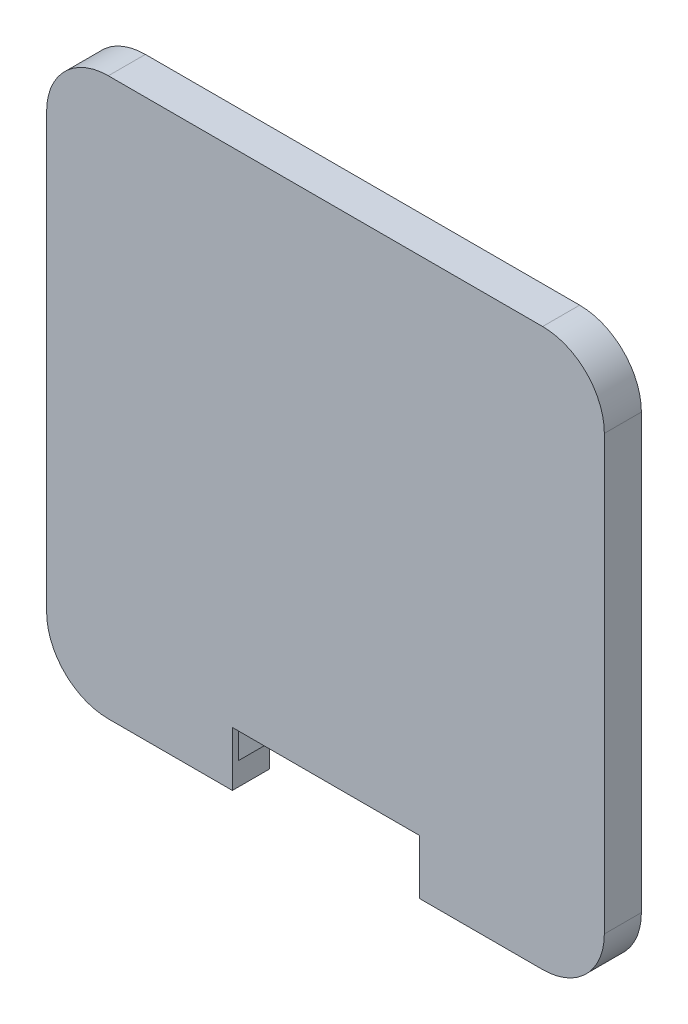
from build123d import *

# Parameters (mm, degrees)
BOSS_EXTRUDE1_DEPTH = 5
BOSS_EXTRUDE2_DEPTH = 1


with BuildPart() as part:
    # Sketch1 → Boss-Extrude1 (new body)
    with BuildSketch(Plane.XY):
        with BuildLine():
            Line((19.723160965, -30.122), (15.214660965, -41.425))
            Line((15.214660965, -41.425), (15.214660965, -45.122))
            Line((15.214660965, -45.122), (35.1855, -45.122))
            ThreePointArc((35.1855, -45.122), (42.256567812, -42.193067812), (45.1855, -35.122))
            Line((45.1855, -35.122), (45.1855, -30.122))
            Line((45.1855, -30.122), (45.1855, 35.122))
            ThreePointArc((45.1855, 35.122), (42.256567812, 42.193067812), (35.1855, 45.122))
            Line((35.1855, 45.122), (-35.1855, 45.122))
            ThreePointArc((-35.1855, 45.122), (-42.256567812, 42.193067812), (-45.1855, 35.122))
            Line((-45.1855, 35.122), (-45.1855, -30.122))
            Line((-45.1855, -30.122), (-45.1855, -35.122))
            ThreePointArc((-45.1855, -35.122), (-42.256567812, -42.193067812), (-35.1855, -45.122))
            Line((-35.1855, -45.122), (-15.086607553, -45.122))
            Line((-15.086607553, -45.122), (-15.086607553, -41.425))
            Line((-15.086607553, -41.425), (-19.722107553, -30.122))
            Line((-19.722107553, -30.122), (-24.9555, -30.122))
            ThreePointArc((-24.9555, -30.122), (-28.653668466, -28.590168466), (-30.1855, -24.892))
            Line((-30.1855, -24.892), (-30.1855, 24.892))
            ThreePointArc((-30.1855, 24.892), (-28.653668466, 28.590168466), (-24.9555, 30.122))
            Line((-24.9555, 30.122), (24.9555, 30.122))
            ThreePointArc((24.9555, 30.122), (28.653668466, 28.590168466), (30.1855, 24.892))
            Line((30.1855, 24.892), (30.1855, -24.892))
            ThreePointArc((30.1855, -24.892), (28.653668466, -28.590168466), (24.9555, -30.122))
            Line((24.9555, -30.122), (19.723160965, -30.122))
        make_face()
    extrude(amount=-BOSS_EXTRUDE1_DEPTH)

    # Sketch2 → Boss-Extrude2 (add)
    with BuildSketch(Plane.XY):
        with BuildLine():
            Line((-24.9555, 30.122), (24.9555, 30.122))
            ThreePointArc((24.9555, 30.122), (28.653668466, 28.590168466), (30.1855, 24.892))
            Line((30.1855, 24.892), (30.1855, -24.892))
            ThreePointArc((30.1855, -24.892), (28.653668466, -28.590168466), (24.9555, -30.122))
            Line((24.9555, -30.122), (19.723160965, -30.122))
            Line((19.723160965, -30.122), (15.214660965, -41.425))
            Line((15.214660965, -41.425), (15.214660965, -45.122))
            Line((15.214660965, -45.122), (35.1855, -45.122))
            ThreePointArc((35.1855, -45.122), (42.256567812, -42.193067812), (45.1855, -35.122))
            Line((45.1855, -35.122), (45.1855, 35.122))
            ThreePointArc((45.1855, 35.122), (42.256567812, 42.193067812), (35.1855, 45.122))
            Line((35.1855, 45.122), (-35.1855, 45.122))
            ThreePointArc((-35.1855, 45.122), (-42.256567812, 42.193067812), (-45.1855, 35.122))
            Line((-45.1855, 35.122), (-45.1855, -35.122))
            ThreePointArc((-45.1855, -35.122), (-42.256567812, -42.193067812), (-35.1855, -45.122))
            Line((-35.1855, -45.122), (-15.086607553, -45.122))
            Line((-15.086607553, -45.122), (-15.086607553, -41.425))
            Line((-15.086607553, -41.425), (-19.722107553, -30.122))
            Line((-19.722107553, -30.122), (-24.9555, -30.122))
            ThreePointArc((-24.9555, -30.122), (-28.653668466, -28.590168466), (-30.1855, -24.892))
            Line((-30.1855, -24.892), (-30.1855, 24.892))
            ThreePointArc((-30.1855, 24.892), (-28.653668466, 28.590168466), (-24.9555, 30.122))
        make_face()
        with BuildLine():
            Line((-19.722107553, -30.122), (-15.086607553, -41.425))
            Line((-15.086607553, -41.425), (-15.086607553, -36.275))
            Line((-15.086607553, -36.275), (15.214660965, -36.275))
            Line((15.214660965, -36.275), (15.214660965, -41.425))
            Line((15.214660965, -41.425), (19.723160965, -30.122))
            Line((19.723160965, -30.122), (24.9555, -30.122))
            ThreePointArc((24.9555, -30.122), (28.653668466, -28.590168466), (30.1855, -24.892))
            Line((30.1855, -24.892), (30.1855, 24.892))
            ThreePointArc((30.1855, 24.892), (28.653668466, 28.590168466), (24.9555, 30.122))
            Line((24.9555, 30.122), (-24.9555, 30.122))
            ThreePointArc((-24.9555, 30.122), (-28.653668466, 28.590168466), (-30.1855, 24.892))
            Line((-30.1855, 24.892), (-30.1855, -24.892))
            ThreePointArc((-30.1855, -24.892), (-28.653668466, -28.590168466), (-24.9555, -30.122))
            Line((-24.9555, -30.122), (-19.722107553, -30.122))
        make_face()
    extrude(amount=BOSS_EXTRUDE2_DEPTH)


solid = part.part
